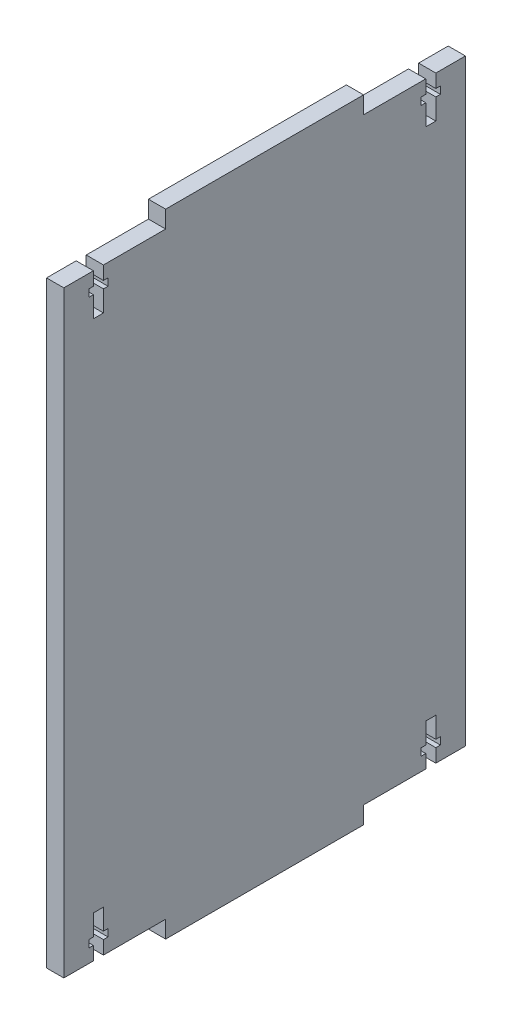
from build123d import *

# Parameters (mm, degrees)
SKETCH1_W           = 119.48
SKETCH1_H           = 177.8
BOSS_EXTRUDE1_DEPTH = 5.13
CUT_EXTRUDE1_DEPTH  = 5.13
SKETCH5_W           = 5.13
SKETCH5_H           = 58.88
BOSS_EXTRUDE2_DEPTH = 5.13
SKETCH8_W           = 5.13
SKETCH8_H           = 58.88
BOSS_EXTRUDE3_DEPTH = 5.13


with BuildPart() as part:
    # Sketch1 → Boss-Extrude1 (new body)
    with BuildSketch(Plane(origin=(0, 0, 0), x_dir=(0, 0, -1), z_dir=(1, 0, 0))):
        with Locations((24.047197546, -50.943101868)):
            Rectangle(SKETCH1_W, SKETCH1_H)
    extrude(amount=BOSS_EXTRUDE1_DEPTH)

    # Sketch2 → Cut-Extrude1 (cut)
    with BuildSketch(Plane(origin=(5.13, 0, 0), x_dir=(0, 0, -1), z_dir=(1, 0, 0))):
        Polygon((-26.892802454, 37.956898132), (-23.895802454, 37.956898132), (-23.895802454, 33.961898132), (-22.536802454, 33.961898132), (-22.536802454, 31.794898132), (-23.895802454, 31.794898132), (-23.895802454, 25.587898132), (-26.892802454, 25.587898132), (-26.892802454, 31.794898132), (-28.251802454, 31.794898132), (-28.251802454, 33.961898132), (-26.892802454, 33.961898132), align=None)
        Polygon((71.987197546, 33.961898132), (71.987197546, 37.956898132), (74.984197546, 37.956898132), (74.984197546, 33.961898132), (76.343197546, 33.961898132), (76.343197546, 31.794898132), (74.984197546, 31.794898132), (74.984197546, 25.587898132), (71.987197546, 25.587898132), (71.987197546, 31.794898132), (70.628197546, 31.794898132), (70.628197546, 33.961898132), align=None)
        Polygon((76.343197546, -133.681101868), (74.984197546, -133.681101868), (74.984197546, -127.474101868), (71.987197546, -127.474101868), (71.987197546, -133.681101868), (70.628197546, -133.681101868), (70.628197546, -135.848101868), (71.987197546, -135.848101868), (71.987197546, -139.843101868), (74.984197546, -139.843101868), (74.984197546, -135.848101868), (76.343197546, -135.848101868), align=None)
        Polygon((-26.892802454, -139.843101868), (-23.895802454, -139.843101868), (-23.895802454, -135.848101868), (-22.536802454, -135.848101868), (-22.536802454, -133.681101868), (-23.895802454, -133.681101868), (-23.895802454, -127.474101868), (-26.892802454, -127.474101868), (-26.892802454, -133.681101868), (-28.251802454, -133.681101868), (-28.251802454, -135.848101868), (-26.892802454, -135.848101868), align=None)
    extrude(amount=-CUT_EXTRUDE1_DEPTH, mode=Mode.SUBTRACT)

    # Sketch5 → Boss-Extrude2 (add)
    with BuildSketch(Plane(origin=(0, 37.956898132, 0), x_dir=(1, 0, 0), z_dir=(0, 1, 0))):
        with Locations((2.565, 24.047197546)):
            Rectangle(SKETCH5_W, SKETCH5_H)
    extrude(amount=BOSS_EXTRUDE2_DEPTH)

    # Sketch8 → Boss-Extrude3 (add)
    with BuildSketch(Plane.XZ.offset(139.843101868)):
        with Locations((2.565, -24.047197546)):
            Rectangle(SKETCH8_W, SKETCH8_H)
    extrude(amount=BOSS_EXTRUDE3_DEPTH)


solid = part.part
